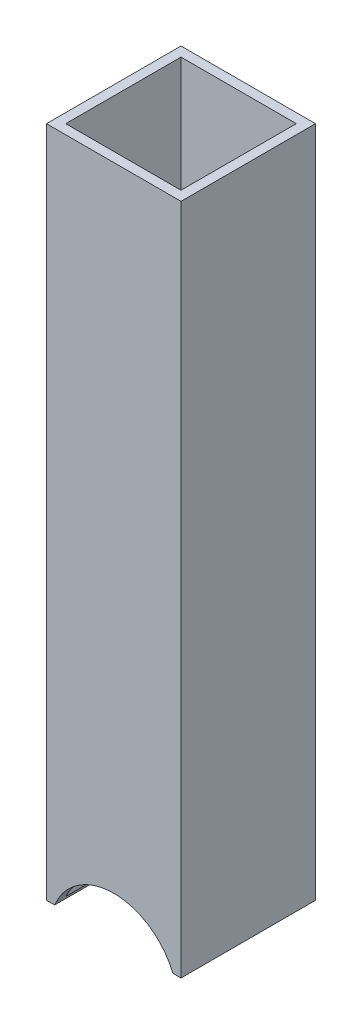
from build123d import *

# Parameters (mm, degrees)
BOSS_EXTRUDE1_DEPTH      = 95.25
BOSS_EXTRUDE1_DEPTH_BACK = 95.25
SKETCH1_W                = 44.45
SKETCH1_H                = 44.45
SKETCH1_W_2              = 38.1
SKETCH1_H_2              = 38.1
SKETCH2_W                = 44.45
SKETCH2_H                = 44.45
SKETCH2_W_2              = 38.1
SKETCH2_H_2              = 38.1
BOSS_EXTRUDE2_DEPTH      = 31.75
SKETCH3_R                = 21.082
CUT_EXTRUDE1_DEPTH       = 137.377245628


with BuildPart() as part:
    # Sketch1 → Boss-Extrude1 (new, two sides: drawn at the far end of the back side and taken through both)
    with BuildSketch(Plane(origin=(0, 0, 0), x_dir=(1, 0, 0), z_dir=(0, 1, 0)).offset(-BOSS_EXTRUDE1_DEPTH_BACK)):
        Rectangle(SKETCH1_W, SKETCH1_H)
        Rectangle(SKETCH1_W_2, SKETCH1_H_2, mode=Mode.SUBTRACT)
    extrude(amount=BOSS_EXTRUDE1_DEPTH + BOSS_EXTRUDE1_DEPTH_BACK)

    # Sketch2 → Boss-Extrude2 (add)
    with BuildSketch(Plane.XZ.offset(95.25)):
        Rectangle(SKETCH2_W, SKETCH2_H)
        Rectangle(SKETCH2_W_2, SKETCH2_H_2, mode=Mode.SUBTRACT)
    extrude(amount=BOSS_EXTRUDE2_DEPTH)

    # Sketch3 → Cut-Extrude1 (cut, through all)
    with BuildSketch(Plane.XY.offset(22.225)):
        with Locations((0, -134.9375)):
            Circle(SKETCH3_R)
    extrude(amount=-CUT_EXTRUDE1_DEPTH, mode=Mode.SUBTRACT)


solid = part.part
